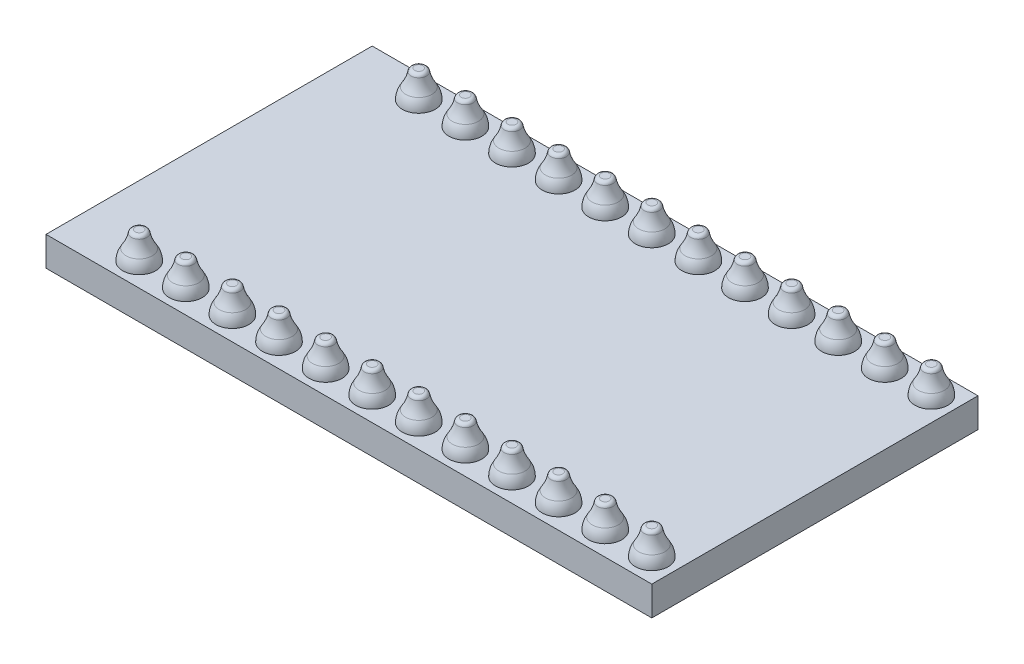
from build123d import *

# Parameters (mm, degrees)
SKETCH1_W            = 33.02
SKETCH1_H            = 17.78
BOSS_EXTRUDE2_DEPTH  = 1.6
SKETCH2_R            = 0.45
CUT_EXTRUDE2_DEPTH   = 1.6
LPATTERN3_COUNT      = 12
LPATTERN3_PITCH      = 2.54
LPATTERN2_COUNT      = 2
LPATTERN2_PITCH      = 15.24
LPATTERN2_COUNT_DIR2 = 12
LPATTERN2_PITCH_DIR2 = 2.54


with BuildPart() as part:
    # Sketch1 → Boss-Extrude2 (new body)
    with BuildSketch(Plane(origin=(0, 0, 0), x_dir=(1, 0, 0), z_dir=(0, 1, 0))):
        with Locations((12.7, 7.62)):
            Rectangle(SKETCH1_W, SKETCH1_H)
    extrude(amount=BOSS_EXTRUDE2_DEPTH)

    # Sketch2 → Cut-Extrude2 (cut)
    with BuildSketch(Plane(origin=(0, 0, 0), x_dir=(1, 0, 0), z_dir=(0, 1, 0))):
        Circle(SKETCH2_R)
        with Locations((0, 15.24)):
            Circle(SKETCH2_R)
    cut_extrude2 = extrude(amount=CUT_EXTRUDE2_DEPTH, mode=Mode.SUBTRACT)

    # LPattern3: Cut-Extrude2 ×12
    with Locations(*[(i * LPATTERN3_PITCH, 0, 0) for i in range(1, LPATTERN3_COUNT)]):
        add(cut_extrude2, mode=Mode.SUBTRACT)

    # Sketch6 → Revolve1 (revolve)
    with BuildSketch(Plane(origin=(0, 0, 0), x_dir=(0, 0, -1), z_dir=(1, 0, 0))):
        with BuildLine():
            Line((0, 1.6), (0.9, 1.6))
            ThreePointArc((0.9, 1.6), (0.852442497, 1.91994498), (0.713882199, 2.212224898))
            ThreePointArc((0.713882199, 2.212224898), (0.530499248, 2.558589224), (0.422081551, 2.93520993))
            ThreePointArc((0.422081551, 2.93520993), (0.353575878, 3.053365554), (0.225205293, 3.1))
            Line((0.225205293, 3.1), (0, 3.1))
            Line((0, 3.1), (0, 1.6))
        make_face()
    revolve1 = revolve(axis=Axis((0, 1.372239532, 0), (0, 1, 0)))

    # LPattern2: Revolve1 2 × 12
    with Locations(*[(j * LPATTERN2_PITCH_DIR2, 0, -i * LPATTERN2_PITCH) for i in range(LPATTERN2_COUNT) for j in range(LPATTERN2_COUNT_DIR2) if (i, j) != (0, 0)]):
        add(revolve1)


solid = part.part
